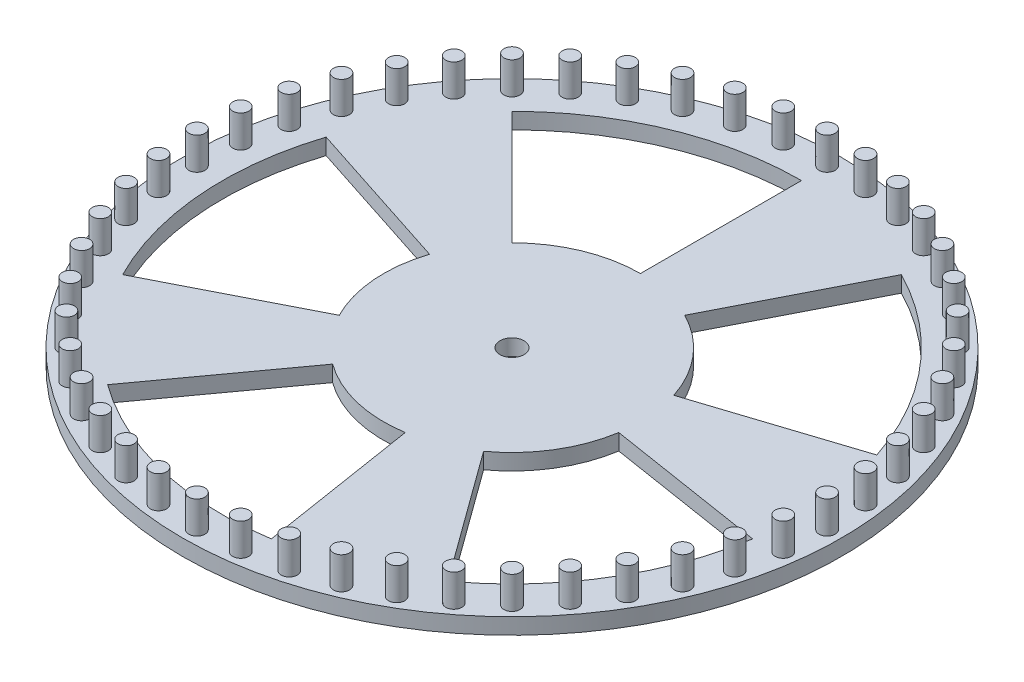
from build123d import *

# Parameters (mm, degrees)
SKETCH1_R         = 130.175
EXTRUDE1_DEPTH    = 6.35
SKETCH3_R         = 4.7625
EXTRUDE3_DEPTH    = 6.35
SKETCH2_R         = 3.175
EXTRUDE4_DEPTH    = 12.7
CIRPATTERN1_COUNT = 48
EXTRUDE5_DEPTH    = 19.05
CIRPATTERN2_COUNT = 5


with BuildPart() as part:
    # Sketch1 → Extrude1 (new body)
    with BuildSketch(Plane(origin=(0, 0, 0), x_dir=(1, 0, 0), z_dir=(0, 1, 0))):
        with Locations(Location((19.489328739, 73.663551537, 0), (0, 0, 270))):  # turned: the seam where the file's is
            Circle(SKETCH1_R)
    extrude(amount=EXTRUDE1_DEPTH)

    # Sketch3 → Extrude3 (cut)
    with BuildSketch(Plane(origin=(0, 6.35, 0), x_dir=(1, 0, 0), z_dir=(0, 1, 0))):
        with Locations(Location((19.489328739, 73.663551537, 0), (0, 0, 270))):  # turned: the seam where the file's is
            Circle(SKETCH3_R)
    extrude(amount=-EXTRUDE3_DEPTH, mode=Mode.SUBTRACT)

    # Sketch2 → Extrude4 (add)
    with BuildSketch(Plane(origin=(0, 6.35, 0), x_dir=(-1, 0, 0), z_dir=(0, 1, 0))):
        with Locations(Location((-143.949328739, -73.663551537, 0), (0, 0, 90))):  # turned: the seam where the file's is
            Circle(SKETCH2_R)
    extrude4 = extrude(amount=EXTRUDE4_DEPTH)

    # CirPattern1: Extrude4 ×48 about axis
    cirpattern1_axis = Axis((19.489328739, 0, -73.663551537), (0, 1, 0))
    for i in range(1, CIRPATTERN1_COUNT):
        add(extrude4.rotate(cirpattern1_axis, i * 360 / CIRPATTERN1_COUNT))

    # Sketch5 → Extrude5 (cut)
    with BuildSketch(Plane(origin=(0, 6.35, 0), x_dir=(1, 0, 0), z_dir=(0, 1, 0))):
        with BuildLine():
            Line((-16.382042301, 109.534922577), (-61.369324084, 154.52220436))
            ThreePointArc((-61.369324084, 154.52220436), (-24.271058832, 179.310472705), (19.489328739, 188.014954995))
            Line((19.489328739, 188.014954995), (19.489328739, 124.393330962))
            ThreePointArc((19.489328739, 124.393330962), (0.075882625, 120.531756437), (-16.382042301, 109.534922577))
        make_face()
    extrude5 = extrude(amount=-EXTRUDE5_DEPTH, mode=Mode.SUBTRACT)

    # CirPattern2: Extrude5 ×5 about axis
    cirpattern2_axis = Axis((19.489328739, 0, -73.663551537), (0, 1, 0))
    for i in range(1, CIRPATTERN2_COUNT):
        add(extrude5.rotate(cirpattern2_axis, i * 360 / CIRPATTERN2_COUNT), mode=Mode.SUBTRACT)


solid = part.part
